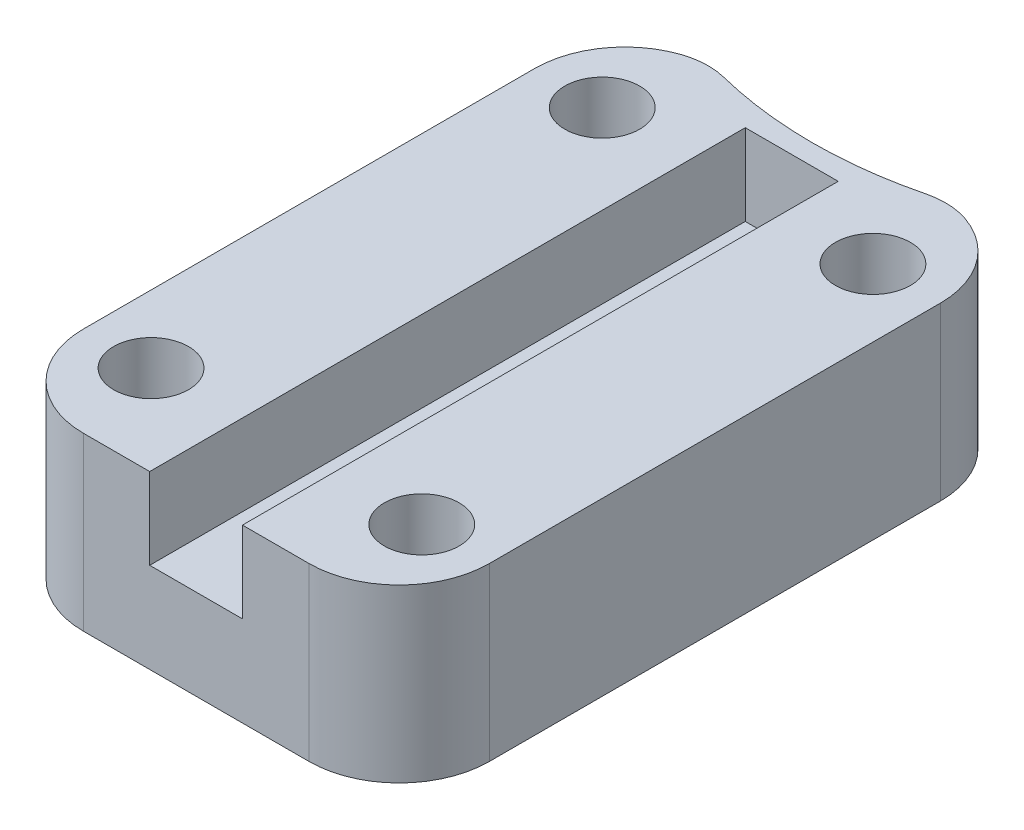
from build123d import *

# Parameters (mm, degrees)
SKETCH1_W           = 45
SKETCH1_H           = 70
BOSS_EXTRUDE1_DEPTH = 10
SKETCH3_R           = 4.15
CUT_EXTRUDE2_DEPTH  = 11
SKETCH5_R           = 4.15
BOSS_EXTRUDE2_DEPTH = 9
CHAMFER1_SIZE       = 1
CHAMFER1_SIZE2      = 1.191753593
FILLET1_R           = 10
CUT_EXTRUDE3_DEPTH  = 20
FILLET2_R           = 8


with BuildPart() as part:
    # Sketch1 → Boss-Extrude1 (new body)
    with BuildSketch(Plane(origin=(0, 0, 0), x_dir=(1, 0, 0), z_dir=(0, 1, 0))):
        Rectangle(SKETCH1_W, SKETCH1_H)
    extrude(amount=BOSS_EXTRUDE1_DEPTH)

    # Sketch3 → Cut-Extrude2 (cut, through all)
    with BuildSketch(Plane.XZ):
        with Locations((15, 25)):
            Circle(SKETCH3_R)
        with Locations((15, -25)):
            Circle(SKETCH3_R)
        with Locations((-15, -25)):
            Circle(SKETCH3_R)
        with Locations((-15, 25)):
            Circle(SKETCH3_R)
    extrude(amount=-CUT_EXTRUDE2_DEPTH, mode=Mode.SUBTRACT)

    # Sketch5 → Boss-Extrude2 (add)
    with BuildSketch(Plane(origin=(0, 10, 0), x_dir=(1, 0, 0), z_dir=(0, 1, 0))):
        Polygon((-5.15, -35), (-22.5, -35), (-22.5, 35), (22.5, 35), (22.5, -35), (5.15, -35), (5.130229348, -34.949305848), (5.15, 31), (-5.15, 31), align=None)
        with Locations((-15, 25)):
            Circle(SKETCH5_R, mode=Mode.SUBTRACT)
        with Locations((15, 25)):
            Circle(SKETCH5_R, mode=Mode.SUBTRACT)
        with Locations((15, -25)):
            Circle(SKETCH5_R, mode=Mode.SUBTRACT)
        with Locations((-15, -25)):
            Circle(SKETCH5_R, mode=Mode.SUBTRACT)
    extrude(amount=BOSS_EXTRUDE2_DEPTH)

    # Chamfer1
    chamfer1_edges = [part.edges().sort_by_distance(p)[0] for p in [
        (-19.15, 0, -25),
        (-19.15, 0, 25),
        (10.85, 0, 25),
        (10.85, 0, -25),
    ]]
    chamfer1_side = [part.faces().sort_by_distance(p)[0] for p in [
        (0, 0, 0),
    ]]
    chamfer(chamfer1_edges, length=CHAMFER1_SIZE, length2=CHAMFER1_SIZE2, reference=chamfer1_side[0])

    # Fillet1
    fillet1_edges = [part.edges().sort_by_distance(p)[0] for p in [
        (-22.5, 9.5, -35),
        (22.5, 9.5, -35),
        (22.5, 9.5, 35),
        (-22.5, 9.5, 35),
    ]]
    fillet(fillet1_edges, radius=FILLET1_R)

    # Sketch6 → Cut-Extrude3 (cut, through all)
    with BuildSketch(Plane(origin=(0, 19, 0), x_dir=(1, 0, 0), z_dir=(0, 1, 0))):
        with BuildLine():
            Line((-12.5, 35), (12.5, 35))
            ThreePointArc((12.5, 35), (0, 33.26906369), (-12.5, 35))
        make_face()
    extrude(amount=-CUT_EXTRUDE3_DEPTH, mode=Mode.SUBTRACT)

    # Fillet2
    fillet2_edges = [part.edges().sort_by_distance(p)[0] for p in [
        (-12.5, 9.5, -35),
        (12.5, 9.5, -35),
    ]]
    fillet(fillet2_edges, radius=FILLET2_R)


solid = part.part
